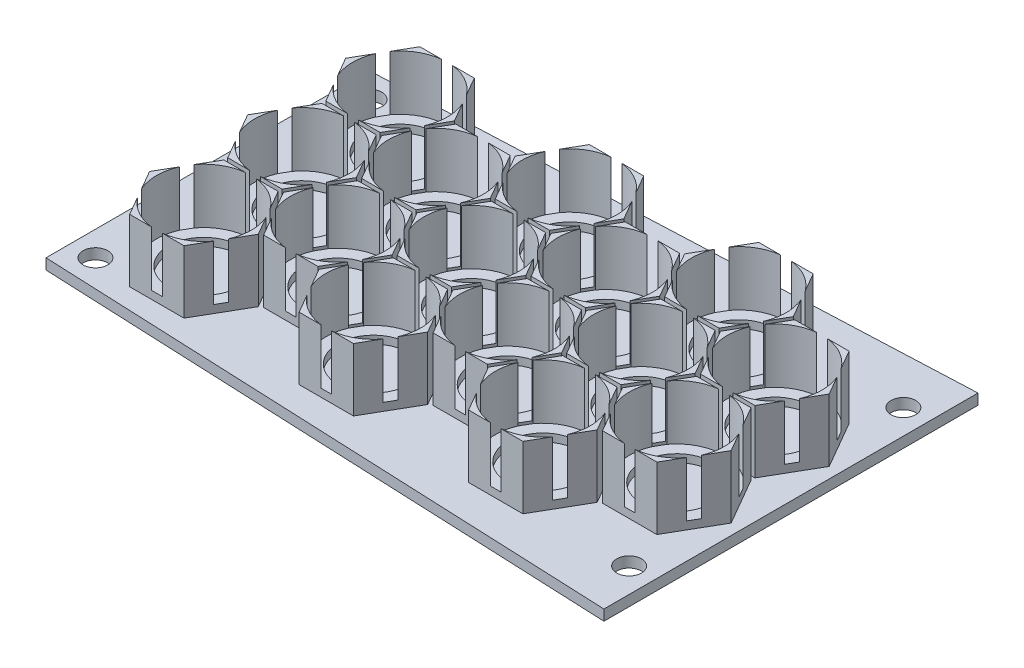
from build123d import *

# Parameters (mm, degrees)
BOSS_EXTRUDE1_DEPTH = 2.15
BOSS_EXTRUDE2_DEPTH = 25.4
SKETCH4_R           = 14.351
CUT_EXTRUDE1_DEPTH  = 25.4
SKETCH4_4_R         = 19.177
CUT_EXTRUDE2_DEPTH  = 22.225
LPATTERN1_COUNT     = 3
LPATTERN1_PITCH     = 68.58
SKETCH6_R           = 5
CUT_EXTRUDE3_DEPTH  = 143.476840223


with BuildPart() as part:
    # Sketch1 → Boss-Extrude1 (new, symmetric)
    with BuildSketch(Plane(origin=(0, 0, 0), x_dir=(1, 0, 0), z_dir=(0, 1, 0))):
        Polygon((-118, 65.5), (-118, -65.5), (118, -75.7), (118, 75.7), align=None)
    extrude(amount=BOSS_EXTRUDE1_DEPTH, both=True)

    # Sketch3 → Boss-Extrude2 (add)
    with BuildSketch(Plane(origin=(0, 2.15, 0), x_dir=(1, 0, 0), z_dir=(0, 1, 0))):
        Polygon((-57.902954744, 39.6875), (-68.901477372, 58.7375), (-90.898522628, 58.7375), (-101.897045256, 39.6875), (-90.898522628, 20.6375), (-68.901477372, 20.6375), align=None)
        Polygon((-57.902954744, 0), (-68.901477372, 19.05), (-90.898522628, 19.05), (-101.897045256, 0), (-90.898522628, -19.05), (-68.901477372, -19.05), align=None)
        Polygon((-68.901477372, -58.7375), (-57.902954744, -39.6875), (-68.901477372, -20.6375), (-90.898522628, -20.6375), (-101.897045256, -39.6875), (-90.898522628, -58.7375), align=None)
        Polygon((-23.532571531, 19.84375), (-34.531094159, 38.89375), (-56.528139415, 38.89375), (-67.526662043, 19.84375), (-56.528139415, 0.79375), (-34.531094159, 0.79375), align=None)
        Polygon((-34.531094159, -38.89375), (-23.532571531, -19.84375), (-34.531094159, -0.79375), (-56.528139415, -0.79375), (-67.526662043, -19.84375), (-56.528139415, -38.89375), align=None)
    boss_extrude2 = extrude(amount=BOSS_EXTRUDE2_DEPTH)

    # Sketch4 → Cut-Extrude1 (cut)
    with BuildSketch(Plane(origin=(0, 27.55, 0), x_dir=(1, 0, 0), z_dir=(0, 1, 0))):
        with Locations((-79.9, 0)):
            Circle(SKETCH4_R)
        with Locations((-79.9, -39.6875)):
            Circle(SKETCH4_R)
        with Locations((-79.9, 39.6875)):
            Circle(SKETCH4_R)
        with Locations((-45.529616787, 19.84375)):
            Circle(SKETCH4_R)
        with Locations((-45.529616787, -19.84375)):
            Circle(SKETCH4_R)
    cut_extrude1 = extrude(amount=-CUT_EXTRUDE1_DEPTH, mode=Mode.SUBTRACT)

    # Sketch4_4 → Cut-Extrude2 (cut)
    with BuildSketch(Plane(origin=(0, 27.55, 0), x_dir=(1, 0, 0), z_dir=(0, 1, 0))):
        with Locations((-79.9, 0)):
            Circle(SKETCH4_4_R)
        with Locations((-79.9, -39.6875)):
            Circle(SKETCH4_4_R)
        with Locations((-79.9, 39.6875)):
            Circle(SKETCH4_4_R)
        with Locations((-45.529616787, 19.84375)):
            Circle(SKETCH4_4_R)
        with Locations((-45.529616787, -19.84375)):
            Circle(SKETCH4_4_R)
    cut_extrude2 = extrude(amount=-CUT_EXTRUDE2_DEPTH, mode=Mode.SUBTRACT)

    # LPattern1: Boss-Extrude2, Cut-Extrude1, Cut-Extrude2 ×3
    with Locations(*[(i * LPATTERN1_PITCH, 0, 0) for i in range(1, LPATTERN1_COUNT)]):
        add(boss_extrude2)
        add(cut_extrude1, mode=Mode.SUBTRACT)
        add(cut_extrude2, mode=Mode.SUBTRACT)

    # Sketch6 → Cut-Extrude3 (cut, through all)
    with BuildSketch(Plane(origin=(0, 2.15, 0), x_dir=(1, 0, 0), z_dir=(0, 1, 0))):
        with Locations((-108, -55.5)):
            Circle(SKETCH6_R)
        with Locations((-108, 55.5)):
            Circle(SKETCH6_R)
        with Locations((108, -55.5)):
            Circle(SKETCH6_R)
        with Locations((108, 55.5)):
            Circle(SKETCH6_R)
    extrude(amount=-CUT_EXTRUDE3_DEPTH, mode=Mode.SUBTRACT)


solid = part.part
